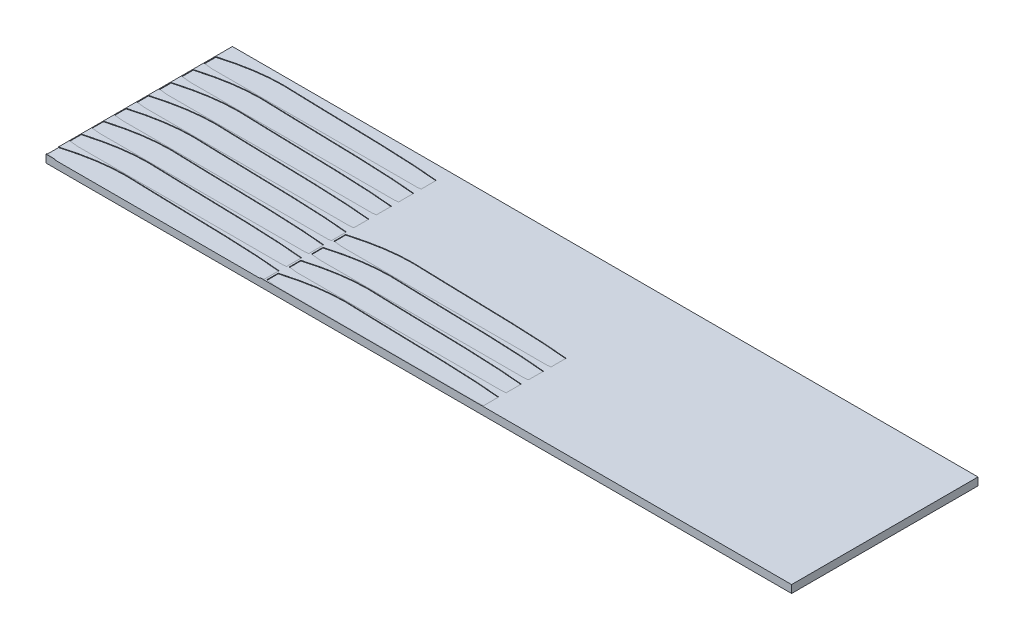
from build123d import *

# Parameters (mm, degrees)
SKETCH1_W           = 304.8
SKETCH1_H           = 76.2
BOSS_EXTRUDE1_DEPTH = 3.175
CUT_EXTRUDE3_DEPTH  = 0.254


with BuildPart() as part:
    # Sketch1 → Boss-Extrude1 (new body)
    with BuildSketch(Plane(origin=(0, 0, 0), x_dir=(1, 0, 0), z_dir=(0, 1, 0))):
        with Locations((-152.4, 38.1)):
            Rectangle(SKETCH1_W, SKETCH1_H)
    extrude(amount=BOSS_EXTRUDE1_DEPTH)

    # Sketch2 → Cut-Extrude3 (cut)
    with BuildSketch(Plane(origin=(0, 3.175, 0), x_dir=(1, 0, 0), z_dir=(0, 1, 0))):
        with BuildLine():
            Line((-304.8, 5.132354223), (-304.8, 0.390438323))
            add(Edge.make_bspline(
                [(-304.8, 0.390438323), (-303.821243343, 0.22923291), (-302.632591032, 0.100235841), (-301.136713645, 0)],
                knots=[0.767987957, 0.767987957, 0.767987957, 0.767987957, 1, 1, 1, 1], degree=3))
            Line((-301.136713645, 0), (-217.379871236, 0))
            add(Edge.make_bspline(
                [(-215.9, 0.210253502), (-216.602591478, 0.075926224), (-217.379871236, 0)],
                knots=[0.882956558, 0.882956558, 0.882956558, 1, 1, 1], degree=2))
            Line((-215.9, 0.210253502), (-215.9, 6.35))
            add(Edge.make_bspline(
                [(-304.8, 5.132354223), (-295.056068779, 7.913424716), (-284.63514545, 9.175759011), (-256.65451685, 7.910717471), (-231.983718042, 8.039058457), (-215.9, 6.35)],
                knots=[0.033341876, 0.033341876, 0.033341876, 0.033341876, 0.196819423, 0.285044024, 0.915587883, 0.915587883, 0.915587883, 0.915587883], degree=3))
        make_face()
        with BuildLine():
            Line((-304.748193138, 14.319973849), (-304.748193138, 9.578057948))
            add(Edge.make_bspline(
                [(-304.748193138, 9.578057948), (-303.76943648, 9.416852535), (-302.58078417, 9.287855466), (-301.084906782, 9.187619625)],
                knots=[0.767987957, 0.767987957, 0.767987957, 0.767987957, 1, 1, 1, 1], degree=3))
            Line((-301.084906782, 9.187619625), (-217.328064374, 9.187619625))
            add(Edge.make_bspline(
                [(-215.848193138, 9.397873128), (-216.550784616, 9.263545849), (-217.328064374, 9.187619625)],
                knots=[0.882956558, 0.882956558, 0.882956558, 1, 1, 1], degree=2))
            Line((-215.848193138, 9.397873128), (-215.848193138, 15.537619625))
            add(Edge.make_bspline(
                [(-304.748193138, 14.319973849), (-295.004261916, 17.101044341), (-284.583338588, 18.363378636), (-256.602709988, 17.098337097), (-231.93191118, 17.226678082), (-215.848193138, 15.537619625)],
                knots=[0.033341876, 0.033341876, 0.033341876, 0.033341876, 0.196819423, 0.285044024, 0.915587883, 0.915587883, 0.915587883, 0.915587883], degree=3))
        make_face()
        with BuildLine():
            Line((-304.77561062, 23.435546339), (-304.77561062, 18.693630439))
            add(Edge.make_bspline(
                [(-304.77561062, 18.693630439), (-303.796853962, 18.532425025), (-302.608201652, 18.403427957), (-301.112324264, 18.303192116)],
                knots=[0.767987957, 0.767987957, 0.767987957, 0.767987957, 1, 1, 1, 1], degree=3))
            Line((-301.112324264, 18.303192116), (-217.355481855, 18.303192116))
            add(Edge.make_bspline(
                [(-215.87561062, 18.513445618), (-216.578202097, 18.37911834), (-217.355481855, 18.303192116)],
                knots=[0.882956558, 0.882956558, 0.882956558, 1, 1, 1], degree=2))
            Line((-215.87561062, 18.513445618), (-215.87561062, 24.653192116))
            add(Edge.make_bspline(
                [(-304.77561062, 23.435546339), (-295.031679398, 26.216616832), (-284.61075607, 27.478951126), (-256.63012747, 26.213909587), (-231.959328661, 26.342250572), (-215.87561062, 24.653192116)],
                knots=[0.033341876, 0.033341876, 0.033341876, 0.033341876, 0.196819423, 0.285044024, 0.915587883, 0.915587883, 0.915587883, 0.915587883], degree=3))
        make_face()
        with BuildLine():
            Line((-304.723803757, 32.623165964), (-304.723803757, 27.881250064))
            add(Edge.make_bspline(
                [(-304.723803757, 27.881250064), (-303.7450471, 27.720044651), (-302.55639479, 27.591047582), (-301.060517402, 27.490811741)],
                knots=[0.767987957, 0.767987957, 0.767987957, 0.767987957, 1, 1, 1, 1], degree=3))
            Line((-301.060517402, 27.490811741), (-217.303674993, 27.490811741))
            add(Edge.make_bspline(
                [(-215.823803757, 27.701065244), (-216.526395235, 27.566737965), (-217.303674993, 27.490811741)],
                knots=[0.882956558, 0.882956558, 0.882956558, 1, 1, 1], degree=2))
            Line((-215.823803757, 27.701065244), (-215.823803757, 33.840811741))
            add(Edge.make_bspline(
                [(-304.723803757, 32.623165964), (-294.979872536, 35.404236457), (-284.558949208, 36.666570752), (-256.578320608, 35.401529213), (-231.907521799, 35.529870198), (-215.823803757, 33.840811741)],
                knots=[0.033341876, 0.033341876, 0.033341876, 0.033341876, 0.196819423, 0.285044024, 0.915587883, 0.915587883, 0.915587883, 0.915587883], degree=3))
        make_face()
        with BuildLine():
            Line((-304.692120731, 41.752034592), (-304.692120731, 37.010118692))
            add(Edge.make_bspline(
                [(-304.692120731, 37.010118692), (-303.713364073, 36.848913278), (-302.524711763, 36.71991621), (-301.028834375, 36.619680369)],
                knots=[0.767987957, 0.767987957, 0.767987957, 0.767987957, 1, 1, 1, 1], degree=3))
            Line((-301.028834375, 36.619680369), (-217.271991966, 36.619680369))
            add(Edge.make_bspline(
                [(-215.792120731, 36.829933871), (-216.494712209, 36.695606593), (-217.271991966, 36.619680369)],
                knots=[0.882956558, 0.882956558, 0.882956558, 1, 1, 1], degree=2))
            Line((-215.792120731, 36.829933871), (-215.792120731, 42.969680369))
            add(Edge.make_bspline(
                [(-304.692120731, 41.752034592), (-294.948189509, 44.533105085), (-284.527266181, 45.795439379), (-256.546637581, 44.53039784), (-231.875838773, 44.658738825), (-215.792120731, 42.969680369)],
                knots=[0.033341876, 0.033341876, 0.033341876, 0.033341876, 0.196819423, 0.285044024, 0.915587883, 0.915587883, 0.915587883, 0.915587883], degree=3))
        make_face()
        with BuildLine():
            Line((-304.640313869, 50.939654217), (-304.640313869, 46.197738317))
            add(Edge.make_bspline(
                [(-304.640313869, 46.197738317), (-303.661557211, 46.036532904), (-302.472904901, 45.907535835), (-300.977027513, 45.807299994)],
                knots=[0.767987957, 0.767987957, 0.767987957, 0.767987957, 1, 1, 1, 1], degree=3))
            Line((-300.977027513, 45.807299994), (-217.220185104, 45.807299994))
            add(Edge.make_bspline(
                [(-215.740313869, 46.017553497), (-216.442905346, 45.883226218), (-217.220185104, 45.807299994)],
                knots=[0.882956558, 0.882956558, 0.882956558, 1, 1, 1], degree=2))
            Line((-215.740313869, 46.017553497), (-215.740313869, 52.157299994))
            add(Edge.make_bspline(
                [(-304.640313869, 50.939654217), (-294.896382647, 53.72072471), (-284.475459319, 54.983059005), (-256.494830719, 53.718017466), (-231.82403191, 53.846358451), (-215.740313869, 52.157299994)],
                knots=[0.033341876, 0.033341876, 0.033341876, 0.033341876, 0.196819423, 0.285044024, 0.915587883, 0.915587883, 0.915587883, 0.915587883], degree=3))
        make_face()
        with BuildLine():
            Line((-304.66773135, 60.055226708), (-304.66773135, 55.313310807))
            add(Edge.make_bspline(
                [(-304.66773135, 55.313310807), (-303.688974693, 55.152105394), (-302.500322383, 55.023108326), (-301.004444995, 54.922872485)],
                knots=[0.767987957, 0.767987957, 0.767987957, 0.767987957, 1, 1, 1, 1], degree=3))
            Line((-301.004444995, 54.922872485), (-217.247602586, 54.922872485))
            add(Edge.make_bspline(
                [(-215.76773135, 55.133125987), (-216.470322828, 54.998798708), (-217.247602586, 54.922872485)],
                knots=[0.882956558, 0.882956558, 0.882956558, 1, 1, 1], degree=2))
            Line((-215.76773135, 55.133125987), (-215.76773135, 61.272872485))
            add(Edge.make_bspline(
                [(-304.66773135, 60.055226708), (-294.923800129, 62.836297201), (-284.502876801, 64.098631495), (-256.522248201, 62.833589956), (-231.851449392, 62.961930941), (-215.76773135, 61.272872485)],
                knots=[0.033341876, 0.033341876, 0.033341876, 0.033341876, 0.196819423, 0.285044024, 0.915587883, 0.915587883, 0.915587883, 0.915587883], degree=3))
        make_face()
        with BuildLine():
            Line((-304.615924488, 69.242846333), (-304.615924488, 64.500930433))
            add(Edge.make_bspline(
                [(-304.615924488, 64.500930433), (-303.637167831, 64.33972502), (-302.448515521, 64.210727951), (-300.952638133, 64.11049211)],
                knots=[0.767987957, 0.767987957, 0.767987957, 0.767987957, 1, 1, 1, 1], degree=3))
            Line((-300.952638133, 64.11049211), (-217.195795724, 64.11049211))
            add(Edge.make_bspline(
                [(-215.715924488, 64.320745612), (-216.418515966, 64.186418334), (-217.195795724, 64.11049211)],
                knots=[0.882956558, 0.882956558, 0.882956558, 1, 1, 1], degree=2))
            Line((-215.715924488, 64.320745612), (-215.715924488, 70.46049211))
            add(Edge.make_bspline(
                [(-304.615924488, 69.242846333), (-294.871993267, 72.023916826), (-284.451069938, 73.286251121), (-256.470441339, 72.021209581), (-231.79964253, 72.149550567), (-215.715924488, 70.46049211)],
                knots=[0.033341876, 0.033341876, 0.033341876, 0.033341876, 0.196819423, 0.285044024, 0.915587883, 0.915587883, 0.915587883, 0.915587883], degree=3))
        make_face()
        with BuildLine():
            Line((-215.183865707, 5.315478387), (-215.183865707, 0.573562486))
            add(Edge.make_bspline(
                [(-215.183865707, 0.573562486), (-214.20510905, 0.412357073), (-213.01645674, 0.283360005), (-211.520579352, 0.183124164)],
                knots=[0.767987957, 0.767987957, 0.767987957, 0.767987957, 1, 1, 1, 1], degree=3))
            Line((-211.520579352, 0.183124164), (-127.763736943, 0.183124164))
            add(Edge.make_bspline(
                [(-126.283865707, 0.393377666), (-126.986457185, 0.259050387), (-127.763736943, 0.183124164)],
                knots=[0.882956558, 0.882956558, 0.882956558, 1, 1, 1], degree=2))
            Line((-126.283865707, 0.393377666), (-126.283865707, 6.533124164))
            add(Edge.make_bspline(
                [(-215.183865707, 5.315478387), (-205.439934486, 8.09654888), (-195.019011157, 9.358883174), (-167.038382558, 8.093841635), (-142.367583749, 8.22218262), (-126.283865707, 6.533124164)],
                knots=[0.033341876, 0.033341876, 0.033341876, 0.033341876, 0.196819423, 0.285044024, 0.915587883, 0.915587883, 0.915587883, 0.915587883], degree=3))
        make_face()
        with BuildLine():
            Line((-215.132058845, 14.503098012), (-215.132058845, 9.761182112))
            add(Edge.make_bspline(
                [(-215.132058845, 9.761182112), (-214.153302188, 9.599976698), (-212.964649877, 9.47097963), (-211.46877249, 9.370743789)],
                knots=[0.767987957, 0.767987957, 0.767987957, 0.767987957, 1, 1, 1, 1], degree=3))
            Line((-211.46877249, 9.370743789), (-127.711930081, 9.370743789))
            add(Edge.make_bspline(
                [(-126.232058845, 9.580997291), (-126.934650323, 9.446670013), (-127.711930081, 9.370743789)],
                knots=[0.882956558, 0.882956558, 0.882956558, 1, 1, 1], degree=2))
            Line((-126.232058845, 9.580997291), (-126.232058845, 15.720743789))
            add(Edge.make_bspline(
                [(-215.132058845, 14.503098012), (-205.388127624, 17.284168505), (-194.967204295, 18.546502799), (-166.986575695, 17.28146126), (-142.315776887, 17.409802246), (-126.232058845, 15.720743789)],
                knots=[0.033341876, 0.033341876, 0.033341876, 0.033341876, 0.196819423, 0.285044024, 0.915587883, 0.915587883, 0.915587883, 0.915587883], degree=3))
        make_face()
        with BuildLine():
            Line((-215.159476327, 23.618670503), (-215.159476327, 18.876754602))
            add(Edge.make_bspline(
                [(-215.159476327, 18.876754602), (-214.180719669, 18.715549189), (-212.992067359, 18.58655212), (-211.496189971, 18.486316279)],
                knots=[0.767987957, 0.767987957, 0.767987957, 0.767987957, 1, 1, 1, 1], degree=3))
            Line((-211.496189971, 18.486316279), (-127.739347562, 18.486316279))
            add(Edge.make_bspline(
                [(-126.259476327, 18.696569782), (-126.962067804, 18.562242503), (-127.739347562, 18.486316279)],
                knots=[0.882956558, 0.882956558, 0.882956558, 1, 1, 1], degree=2))
            Line((-126.259476327, 18.696569782), (-126.259476327, 24.836316279))
            add(Edge.make_bspline(
                [(-215.159476327, 23.618670503), (-205.415545105, 26.399740996), (-194.994621777, 27.66207529), (-167.013993177, 26.397033751), (-142.343194369, 26.525374736), (-126.259476327, 24.836316279)],
                knots=[0.033341876, 0.033341876, 0.033341876, 0.033341876, 0.196819423, 0.285044024, 0.915587883, 0.915587883, 0.915587883, 0.915587883], degree=3))
        make_face()
        with BuildLine():
            Line((-215.107669465, 32.806290128), (-215.107669465, 28.064374228))
            add(Edge.make_bspline(
                [(-215.107669465, 28.064374228), (-214.128912807, 27.903168814), (-212.940260497, 27.774171746), (-211.444383109, 27.673935905)],
                knots=[0.767987957, 0.767987957, 0.767987957, 0.767987957, 1, 1, 1, 1], degree=3))
            Line((-211.444383109, 27.673935905), (-127.6875407, 27.673935905))
            add(Edge.make_bspline(
                [(-126.207669465, 27.884189407), (-126.910260942, 27.749862129), (-127.6875407, 27.673935905)],
                knots=[0.882956558, 0.882956558, 0.882956558, 1, 1, 1], degree=2))
            Line((-126.207669465, 27.884189407), (-126.207669465, 34.023935905))
            add(Edge.make_bspline(
                [(-215.107669465, 32.806290128), (-205.363738243, 35.587360621), (-194.942814915, 36.849694915), (-166.962186315, 35.584653376), (-142.291387506, 35.712994361), (-126.207669465, 34.023935905)],
                knots=[0.033341876, 0.033341876, 0.033341876, 0.033341876, 0.196819423, 0.285044024, 0.915587883, 0.915587883, 0.915587883, 0.915587883], degree=3))
        make_face()
    extrude(amount=-CUT_EXTRUDE3_DEPTH, mode=Mode.SUBTRACT)


solid = part.part
